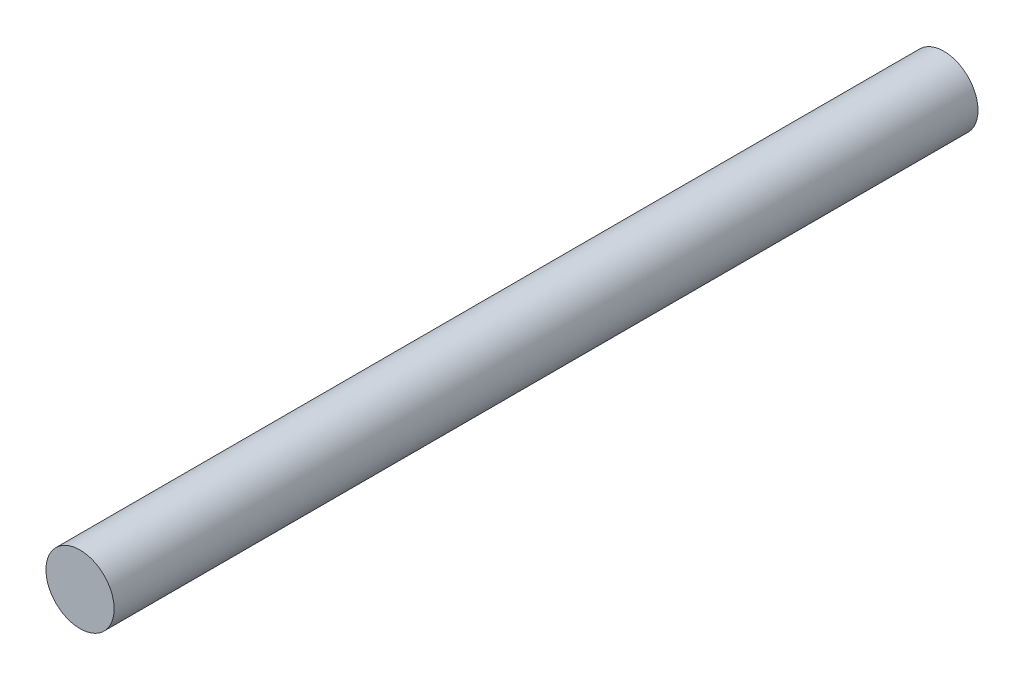
from build123d import *

# Parameters (mm, degrees)
SKETCH1_R           = 1.5
BOSS_EXTRUDE1_DEPTH = 38


with BuildPart() as part:
    # Sketch1 → Boss-Extrude1 (new body)
    with BuildSketch(Plane.XY):
        Circle(SKETCH1_R)
    extrude(amount=BOSS_EXTRUDE1_DEPTH)


solid = part.part
